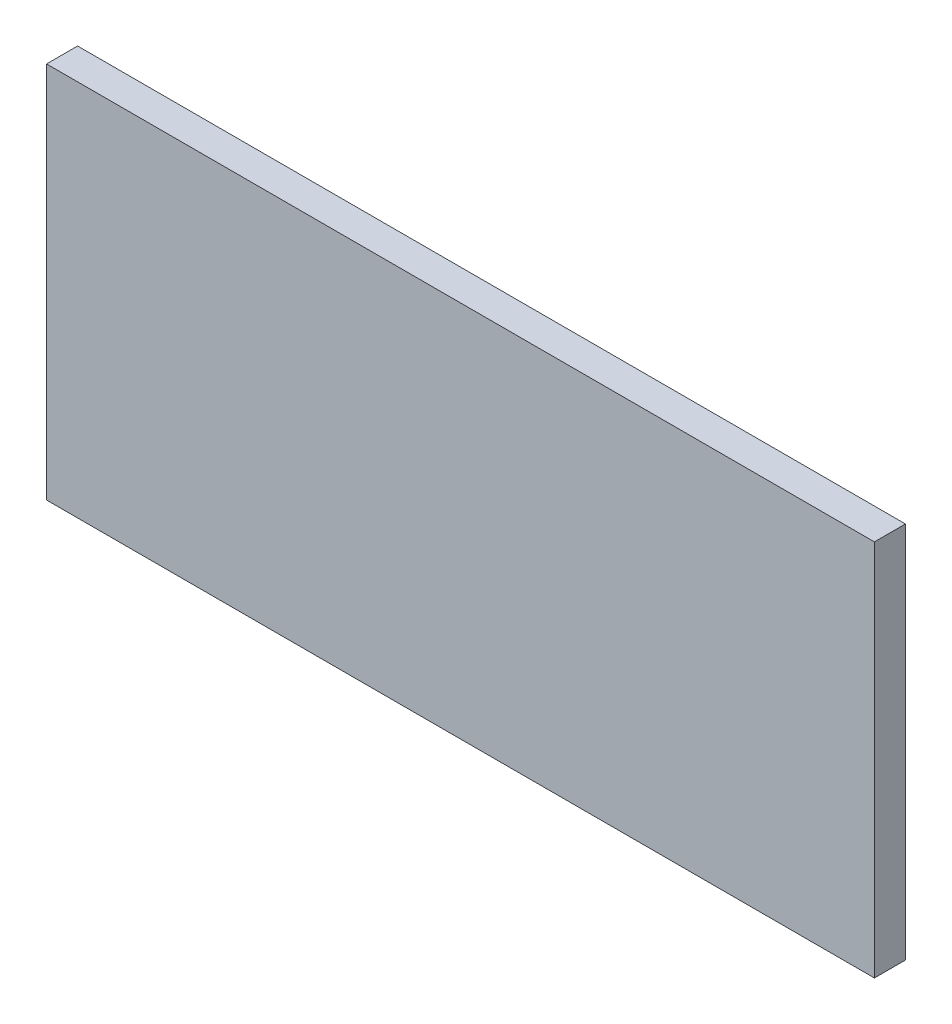
from build123d import *

# Parameters (mm, degrees)
SKETCH1_W           = 80
SKETCH1_H           = 36.5
BOSS_EXTRUDE1_DEPTH = 3


with BuildPart() as part:
    # Sketch1 → Boss-Extrude1 (new body)
    with BuildSketch(Plane.XY):
        with Locations((40, 18.25)):
            Rectangle(SKETCH1_W, SKETCH1_H)
    extrude(amount=-BOSS_EXTRUDE1_DEPTH)


solid = part.part
